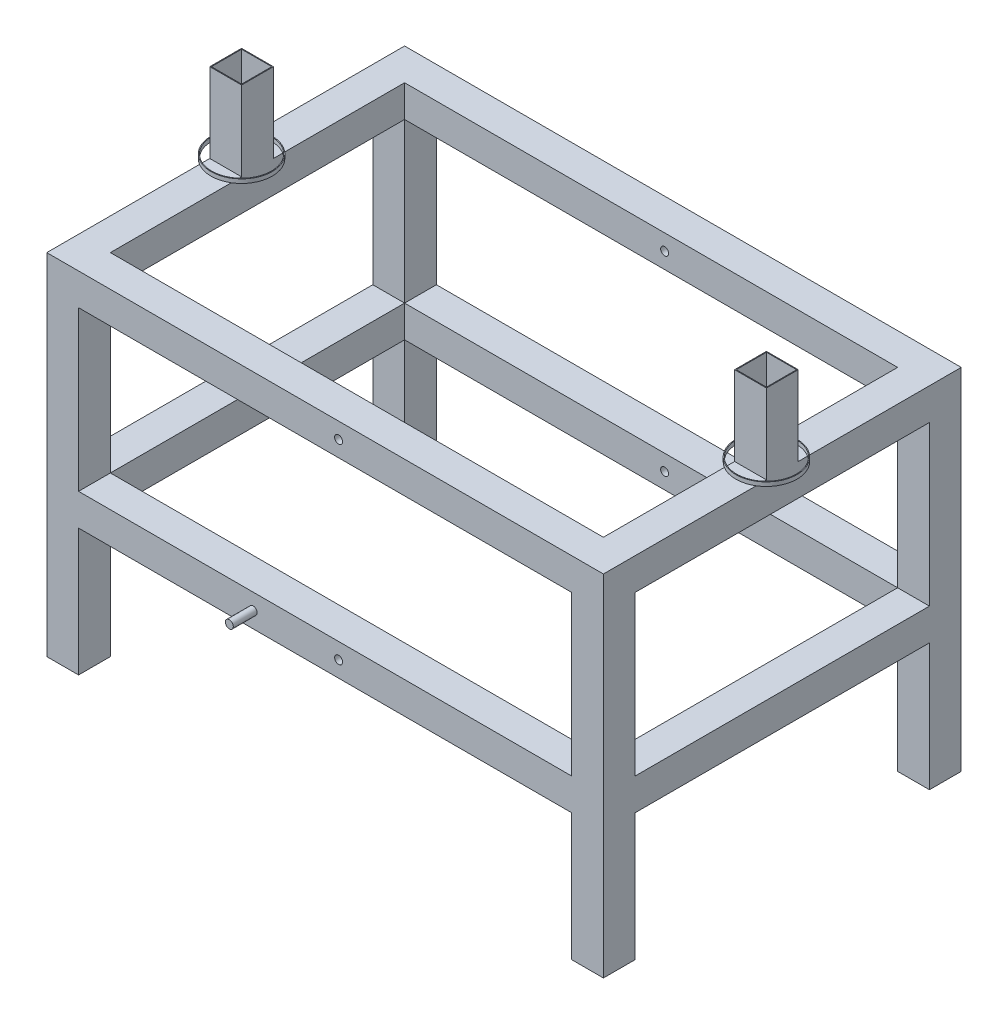
from build123d import *

# Parameters (mm, degrees)
SKETCH1_W             = 40
SKETCH1_H             = 40
SKETCH1_W_2           = 38
SKETCH1_H_2           = 38
BOSS_EXTRUDE1_DEPTH   = 200
BOSS_EXTRUDE1_2_DEPTH = 200
BOSS_EXTRUDE1_3_DEPTH = 200
BOSS_EXTRUDE1_4_DEPTH = 200
SKETCH2_W             = 700
SKETCH2_H             = 450
SKETCH2_W_2           = 620
SKETCH2_H_2           = 370
BOSS_EXTRUDE2_DEPTH   = 40
SKETCH3_W             = 40
SKETCH3_H             = 40
SKETCH3_W_2           = 38
SKETCH3_H_2           = 38
BOSS_EXTRUDE4_DEPTH   = 100
SKETCH4_R             = 5
CUT_EXTRUDE1_DEPTH    = 465
SKETCH5_W             = 700
SKETCH5_H             = 450
SKETCH5_W_2           = 620
SKETCH5_H_2           = 370
BOSS_EXTRUDE5_DEPTH   = 40
SKETCH6_R             = 5
CUT_EXTRUDE2_DEPTH    = 508
SKETCH7_R             = 38.5
SKETCH7_R_2           = 37.5
BOSS_EXTRUDE6_DEPTH   = 5
SKETCH8_R             = 5
BOSS_EXTRUDE7_DEPTH   = 30


with BuildPart() as part:
    # Sketch1 → Boss-Extrude1 (new body, symmetric)
    with BuildSketch(Plane(origin=(0, 0, 0), x_dir=(1, 0, 0), z_dir=(0, 1, 0))):
        with Locations((-330, 205)):
            Rectangle(SKETCH1_W, SKETCH1_H)
        with Locations((-330, 205)):
            Rectangle(SKETCH1_W_2, SKETCH1_H_2, mode=Mode.SUBTRACT)
    extrude(amount=BOSS_EXTRUDE1_DEPTH, both=True)



with BuildPart() as body_2:
    # Sketch1 → Boss-Extrude1 2 (new body, symmetric)
    with BuildSketch(Plane(origin=(0, 0, 0), x_dir=(1, 0, 0), z_dir=(0, 1, 0))):
        with Locations((330, 205)):
            Rectangle(SKETCH1_W, SKETCH1_H)
        with Locations((330, 205)):
            Rectangle(SKETCH1_W_2, SKETCH1_H_2, mode=Mode.SUBTRACT)
    extrude(amount=BOSS_EXTRUDE1_2_DEPTH, both=True)


with BuildPart() as body_3:
    # Sketch1 → Boss-Extrude1 3 (new body, symmetric)
    with BuildSketch(Plane(origin=(0, 0, 0), x_dir=(1, 0, 0), z_dir=(0, 1, 0))):
        with Locations((330, -205)):
            Rectangle(SKETCH1_W, SKETCH1_H)
        with Locations((330, -205)):
            Rectangle(SKETCH1_W_2, SKETCH1_H_2, mode=Mode.SUBTRACT)
    extrude(amount=BOSS_EXTRUDE1_3_DEPTH, both=True)


with BuildPart() as body_4:
    # Sketch1 → Boss-Extrude1 4 (new body, symmetric)
    with BuildSketch(Plane(origin=(0, 0, 0), x_dir=(1, 0, 0), z_dir=(0, 1, 0))):
        with Locations((-330, -205)):
            Rectangle(SKETCH1_W, SKETCH1_H)
        with Locations((-330, -205)):
            Rectangle(SKETCH1_W_2, SKETCH1_H_2, mode=Mode.SUBTRACT)
    extrude(amount=BOSS_EXTRUDE1_4_DEPTH, both=True)


with BuildPart() as part_1:
    add(part.part)

    add(body_2.part)  # Boss-Extrude2 merges body 2

    add(body_3.part)  # Boss-Extrude2 merges body 3

    add(body_4.part)  # Boss-Extrude2 merges body 4
    # Sketch2 → Boss-Extrude2 (add)
    with BuildSketch(Plane(origin=(0, 200, 0), x_dir=(1, 0, 0), z_dir=(0, 1, 0))):
        Rectangle(SKETCH2_W, SKETCH2_H)
        Rectangle(SKETCH2_W_2, SKETCH2_H_2, mode=Mode.SUBTRACT)
    extrude(amount=BOSS_EXTRUDE2_DEPTH)

    # Sketch3 → Boss-Extrude4 (add)
    with BuildSketch(Plane(origin=(0, 240, 0), x_dir=(1, 0, 0), z_dir=(0, 1, 0))):
        with Locations((-330, 0)):
            Rectangle(SKETCH3_W, SKETCH3_H)
        with Locations((-330, 0)):
            Rectangle(SKETCH3_W_2, SKETCH3_H_2, mode=Mode.SUBTRACT)
        with Locations((330, 0)):
            Rectangle(SKETCH3_W, SKETCH3_H)
        with Locations((330, 0)):
            Rectangle(SKETCH3_W_2, SKETCH3_H_2, mode=Mode.SUBTRACT)
    extrude(amount=BOSS_EXTRUDE4_DEPTH)

    # Sketch4 → Cut-Extrude1 (cut)
    with BuildSketch(Plane.XY.offset(225)):
        with Locations((17, 220)):
            Circle(SKETCH4_R)
    extrude(amount=-CUT_EXTRUDE1_DEPTH, mode=Mode.SUBTRACT)

    # Sketch5 → Boss-Extrude5 (add)
    with BuildSketch(Plane(origin=(0, 0, 0), x_dir=(1, 0, 0), z_dir=(0, 1, 0))):
        Rectangle(SKETCH5_W, SKETCH5_H)
        Rectangle(SKETCH5_W_2, SKETCH5_H_2, mode=Mode.SUBTRACT)
    extrude(amount=-BOSS_EXTRUDE5_DEPTH)

    # Sketch6 → Cut-Extrude2 (cut)
    with BuildSketch(Plane.XY.offset(225)):
        with Locations((17, -20)):
            Circle(SKETCH6_R)
    extrude(amount=-CUT_EXTRUDE2_DEPTH, mode=Mode.SUBTRACT)

    # Sketch7 → Boss-Extrude6 (add)
    with BuildSketch(Plane(origin=(0, 240, 0), x_dir=(1, 0, 0), z_dir=(0, 1, 0))):
        with Locations((-330, 0)):
            Circle(SKETCH7_R)
        with Locations((-330, 0)):
            Circle(SKETCH7_R_2, mode=Mode.SUBTRACT)
        with Locations((330, 0)):
            Circle(SKETCH7_R)
        with Locations((330, 0)):
            Circle(SKETCH7_R_2, mode=Mode.SUBTRACT)
    extrude(amount=BOSS_EXTRUDE6_DEPTH)

    # Sketch8 → Boss-Extrude7 (add)
    with BuildSketch(Plane.XY.offset(225)):
        with Locations((-90.424393733, -20)):
            Circle(SKETCH8_R)
    extrude(amount=BOSS_EXTRUDE7_DEPTH)


solid = part_1.part
